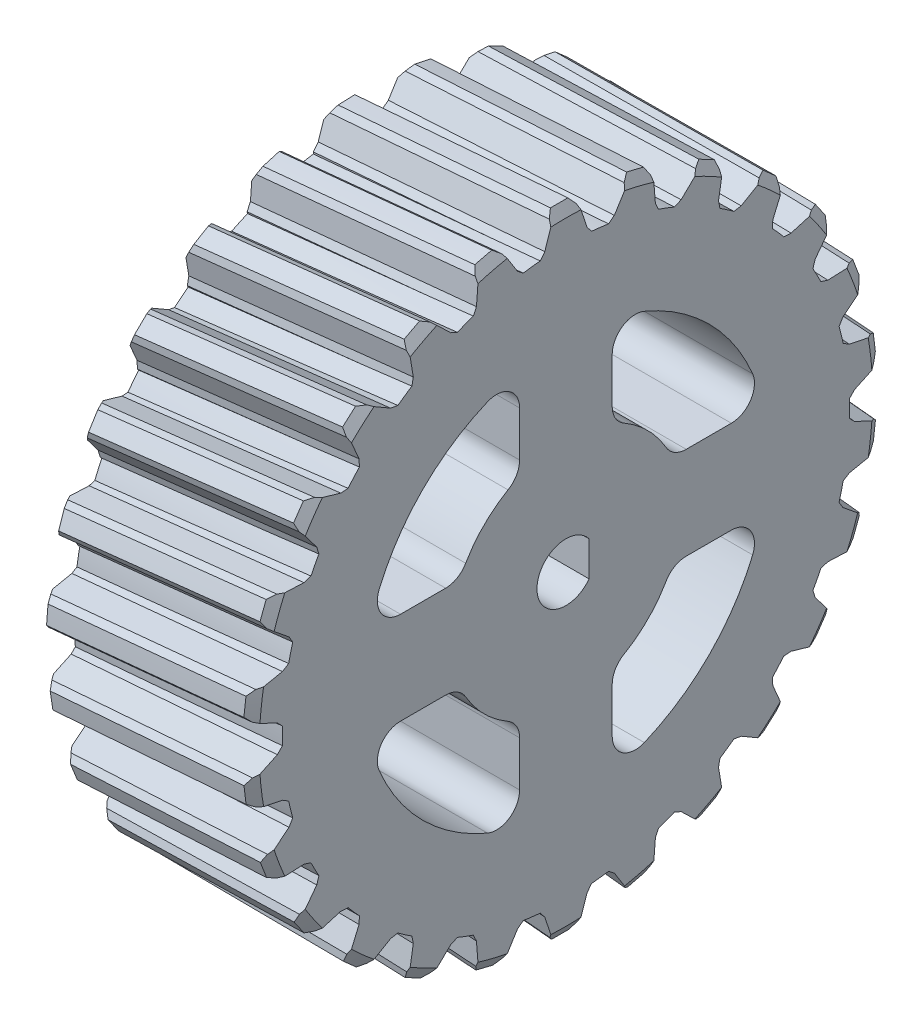
from build123d import *

# Parameters (mm, degrees)
SKETCH1_R           = 24.5
BOSS_EXTRUDE1_DEPTH = 18
CIRPATTERN1_COUNT   = 26


with BuildPart() as part:
    # Sketch1 → Boss-Extrude1 (new body)
    with BuildSketch(Plane(origin=(0, 0, 0), x_dir=(0, 0, -1), z_dir=(1, 0, 0))):
        Circle(SKETCH1_R)
        with BuildLine():
            Line((-4, 10.392304845), (-4, 14.291605928))
            ThreePointArc((-4, 14.291605928), (-4.892838561, 15.957196979), (-6.774193548, 16.135684112))
            ThreePointArc((-6.774193548, 16.135684112), (-12.374368671, 12.374368671), (-16.135684112, 6.774193548))
            ThreePointArc((-16.135684112, 6.774193548), (-15.957196979, 4.892838561), (-14.291605928, 4))
            Line((-14.291605928, 4), (-10.392304845, 4))
            ThreePointArc((-10.392304845, 4), (-9.392304845, 4.267949192), (-8.660254038, 5))
            ThreePointArc((-8.660254038, 5), (-7.071067812, 7.071067812), (-5, 8.660254038))
            ThreePointArc((-5, 8.660254038), (-4.267949192, 9.392304845), (-4, 10.392304845))
        make_face(mode=Mode.SUBTRACT)
        with BuildLine():
            Line((-14.291605928, -4), (-10.392304845, -4))
            ThreePointArc((-10.392304845, -4), (-9.392304845, -4.267949192), (-8.660254038, -5))
            ThreePointArc((-8.660254038, -5), (-7.071067812, -7.071067812), (-5, -8.660254038))
            ThreePointArc((-5, -8.660254038), (-4.267949192, -9.392304845), (-4, -10.392304845))
            Line((-4, -10.392304845), (-4, -14.291605928))
            ThreePointArc((-4, -14.291605928), (-4.892838561, -15.957196979), (-6.774193548, -16.135684112))
            ThreePointArc((-6.774193548, -16.135684112), (-12.374368671, -12.374368671), (-16.135684112, -6.774193548))
            ThreePointArc((-16.135684112, -6.774193548), (-15.957196979, -4.892838561), (-14.291605928, -4))
        make_face(mode=Mode.SUBTRACT)
        with BuildLine():
            Line((2, 1.5), (2, -1.5))
            ThreePointArc((2, -1.5), (-2.5, 0), (2, 1.5))
        make_face(mode=Mode.SUBTRACT)
        with BuildLine():
            Line((4, 10.392304845), (4, 14.291605928))
            ThreePointArc((4, 14.291605928), (4.892838561, 15.957196979), (6.774193548, 16.135684112))
            ThreePointArc((6.774193548, 16.135684112), (12.374368671, 12.374368671), (16.135684112, 6.774193548))
            ThreePointArc((16.135684112, 6.774193548), (15.957196979, 4.892838561), (14.291605928, 4))
            Line((14.291605928, 4), (10.392304845, 4))
            ThreePointArc((10.392304845, 4), (9.392304845, 4.267949192), (8.660254038, 5))
            ThreePointArc((8.660254038, 5), (7.071067812, 7.071067812), (5, 8.660254038))
            ThreePointArc((5, 8.660254038), (4.267949192, 9.392304845), (4, 10.392304845))
        make_face(mode=Mode.SUBTRACT)
        with BuildLine():
            Line((10.392304845, -4), (14.291605928, -4))
            ThreePointArc((14.291605928, -4), (15.957196979, -4.892838561), (16.135684112, -6.774193548))
            ThreePointArc((16.135684112, -6.774193548), (12.374368671, -12.374368671), (6.774193548, -16.135684112))
            ThreePointArc((6.774193548, -16.135684112), (4.892838561, -15.957196979), (4, -14.291605928))
            Line((4, -14.291605928), (4, -10.392304845))
            ThreePointArc((4, -10.392304845), (4.267949192, -9.392304845), (5, -8.660254038))
            ThreePointArc((5, -8.660254038), (7.071067812, -7.071067812), (8.660254038, -5))
            ThreePointArc((8.660254038, -5), (9.392304845, -4.267949192), (10.392304845, -4))
        make_face(mode=Mode.SUBTRACT)
    extrude(amount=BOSS_EXTRUDE1_DEPTH)

    # Sweep1: sweep along a curve in space
    with BuildLine() as sweep1_path:
        Line((18, 27.392276003, 0), (-0.429601915, 27.392276003, 1.612381241))
    # Sketch2 → Sweep1 (sweep)
    with BuildSketch(Plane(origin=(18, 0, 0), x_dir=(0, 0, -1), z_dir=(1, 0, 0))):
        with BuildLine():
            Line((-1.166364622, 26.884273235), (-1.825364997, 24.895147931))
            Line((-1.825364997, 24.895147931), (-2.25, 24.361588477))
            Line((-2.25, 24.361588477), (-2.25, 23.321404177))
            Line((-2.25, 23.321404177), (2.278465042, 23.321404177))
            Line((2.278465042, 23.321404177), (2.278465042, 24.325821778))
            Line((2.278465042, 24.325821778), (1.825364997, 24.895147931))
            Line((1.825364997, 24.895147931), (1.166364622, 26.884273235))
            Line((1.166364622, 26.884273235), (0.75, 27.388986466))
            ThreePointArc((0.75, 27.388986466), (0, 27.392276003), (-0.75, 27.388986466))
            Line((-0.75, 27.388986466), (-1.166364622, 26.884273235))
        make_face()
    sweep1 = sweep(path=sweep1_path.line)

    # CirPattern1: Sweep1 ×26 about axis
    cirpattern1_axis = Axis((0, 0, 0), (-1, 0, 0))
    for i in range(1, CIRPATTERN1_COUNT):
        add(sweep1.rotate(cirpattern1_axis, i * 360 / CIRPATTERN1_COUNT))

    # Sketch4 → Cut-Revolve1 (revolve, cut)
    with BuildSketch(Plane(origin=(0, 0, 0), x_dir=(1, 0, 0), z_dir=(0, 1, 0))):
        Polygon((18, 14.841271499), (18, 26.5), (17.25, 27.75), (0.75, 27.75), (0, 26.5), (0, 14.841271499), (-8.131485338, 14.841271499), (-8.131485338, 41.894345071), (23.949020108, 41.894345071), (23.949020108, 14.841271499), align=None)
    revolve(axis=Axis((0, 0, 0), (1, 0, 0)), mode=Mode.SUBTRACT)


solid = part.part
